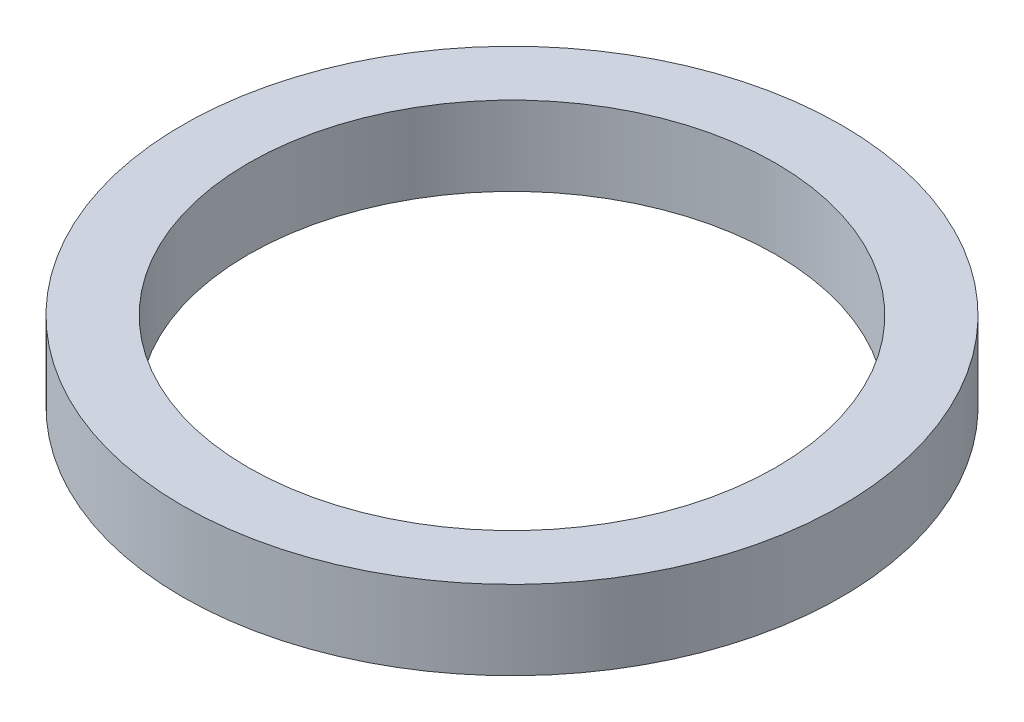
from build123d import *

# Parameters (mm, degrees)
SKETCH1_R           = 25
SKETCH1_R_2         = 20
BOSS_EXTRUDE1_DEPTH = 6


with BuildPart() as part:
    # Sketch1 → Boss-Extrude1 (new body)
    with BuildSketch(Plane(origin=(0, 0, 0), x_dir=(1, 0, 0), z_dir=(0, 1, 0))):
        Circle(SKETCH1_R)
        Circle(SKETCH1_R_2, mode=Mode.SUBTRACT)
    extrude(amount=BOSS_EXTRUDE1_DEPTH)


solid = part.part
